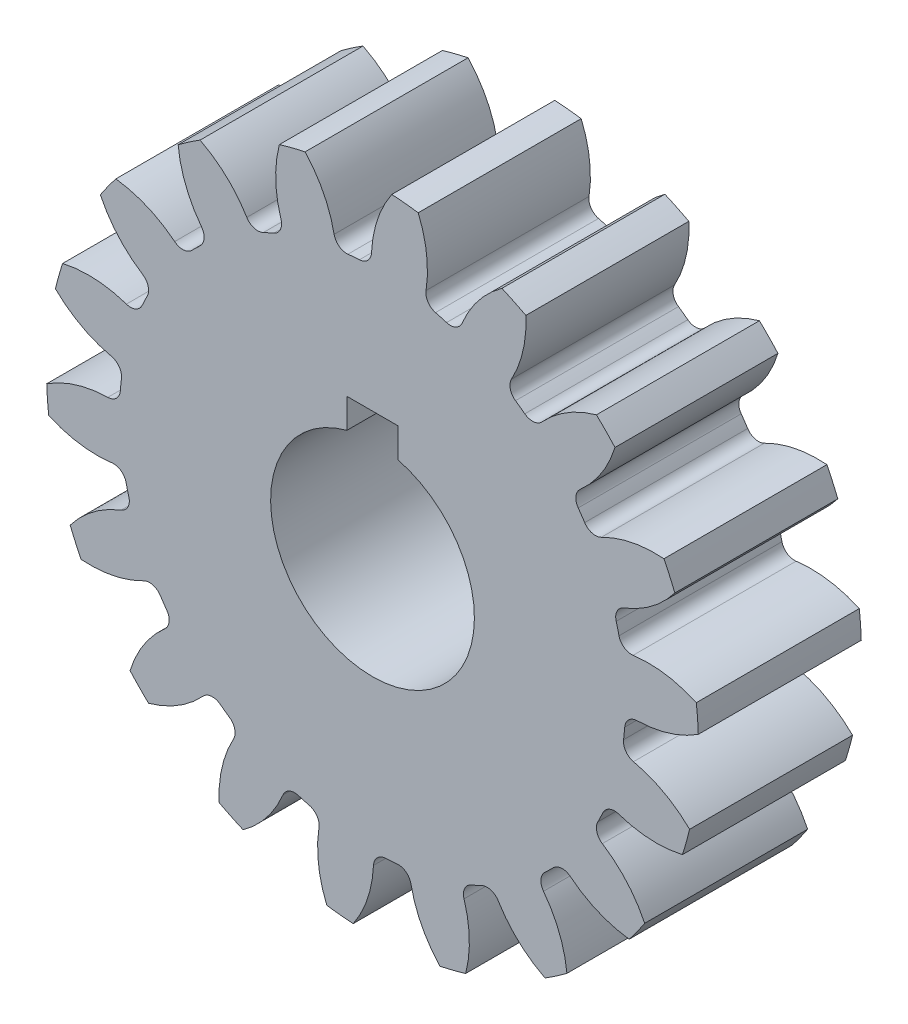
from build123d import *

# Parameters (mm, degrees)
SKETCH3_R         = 12.7
GEARBODY_DEPTH    = 6.35
TOOTHCUT_DEPTH    = 7.35
CIRPATTERN1_COUNT = 18
BORE_DEPTH        = 12.7


with BuildPart() as part:
    # Sketch3 → gearBody (new body)
    with BuildSketch(Plane.XY):
        Circle(SKETCH3_R)
    extrude(amount=GEARBODY_DEPTH)

    # Sketch2 → toothCut (cut, through all)
    with BuildSketch(Plane.XY):
        with BuildLine():
            ThreePointArc((9.781229257, -1.205205904), (9.806057787, -0.982953571), (9.825836884, -0.760195085))
            ThreePointArc((9.825836884, -0.760195085), (9.980803767, -0.435792976), (10.31355819, -0.299682883))
            ThreePointArc((10.31355819, -0.299682883), (12.38209996, 0.246018063), (13.970369973, 1.679214819))
            ThreePointArc((13.970369973, 1.679214819), (14.000763839, -1.403428484), (13.359117821, -4.418706897))
            ThreePointArc((13.359117821, -4.418706897), (12.0869153, -2.698778026), (10.167842346, -1.753360882))
            ThreePointArc((10.167842346, -1.753360882), (9.868724138, -1.553912241), (9.781229257, -1.205205904))
        make_face()
    toothcut = extrude(amount=TOOTHCUT_DEPTH, mode=Mode.SUBTRACT)

    # CirPattern1: toothCut ×18 about axis
    cirpattern1_axis = Axis((0, 0, 0), (0, 0, 1))
    for i in range(1, CIRPATTERN1_COUNT):
        add(toothcut.rotate(cirpattern1_axis, i * 360 / CIRPATTERN1_COUNT), mode=Mode.SUBTRACT)

    # boreDia → bore (cut, symmetric)
    with BuildSketch(Plane.XY):
        with BuildLine():
            Line((-1, 3.842012337), (-1, 4.992632337))
            Line((-1, 4.992632337), (1, 4.992632337))
            Line((1, 4.992632337), (1, 3.842012337))
            ThreePointArc((1, 3.842012337), (0, -3.97002), (-1, 3.842012337))
        make_face()
    extrude(amount=BORE_DEPTH, both=True, mode=Mode.SUBTRACT)


solid = part.part
